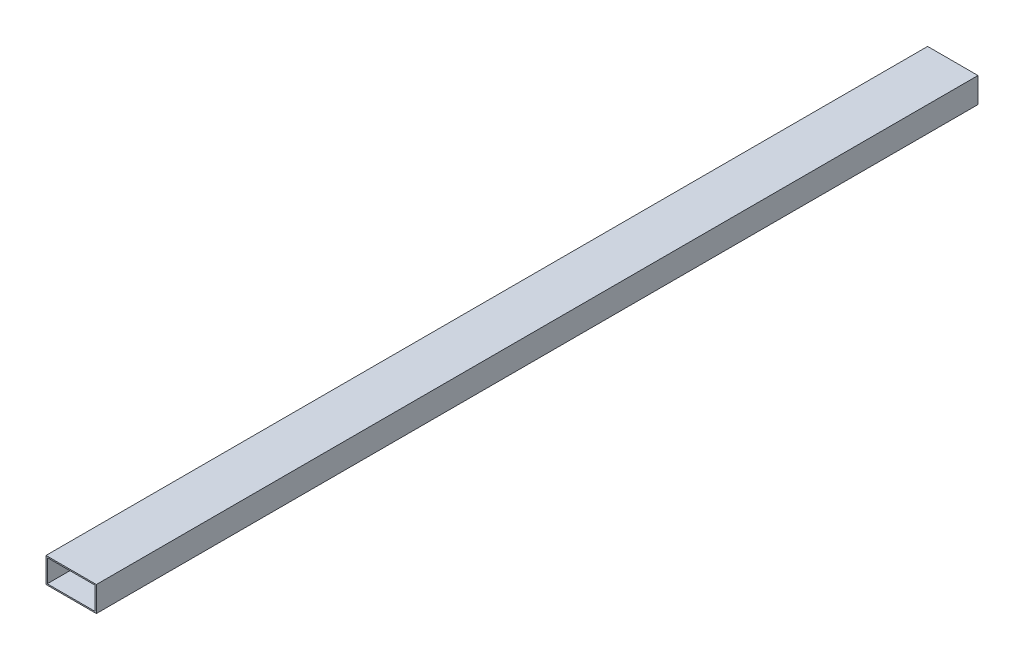
from build123d import *

# Parameters (mm, degrees)
SKETCH1_W           = 40
SKETCH1_H           = 20
BOSS_EXTRUDE1_DEPTH = 700
SKETCH2_W           = 38
SKETCH2_H           = 18
CUT_EXTRUDE1_DEPTH  = 700


with BuildPart() as part:
    # Sketch1 → Boss-Extrude1 (new body)
    with BuildSketch(Plane.XY):
        Rectangle(SKETCH1_W, SKETCH1_H)
    extrude(amount=BOSS_EXTRUDE1_DEPTH)

    # Sketch2 → Cut-Extrude1 (cut)
    with BuildSketch(Plane.XY.offset(700)):
        Rectangle(SKETCH2_W, SKETCH2_H)
    extrude(amount=-CUT_EXTRUDE1_DEPTH, mode=Mode.SUBTRACT)


solid = part.part
